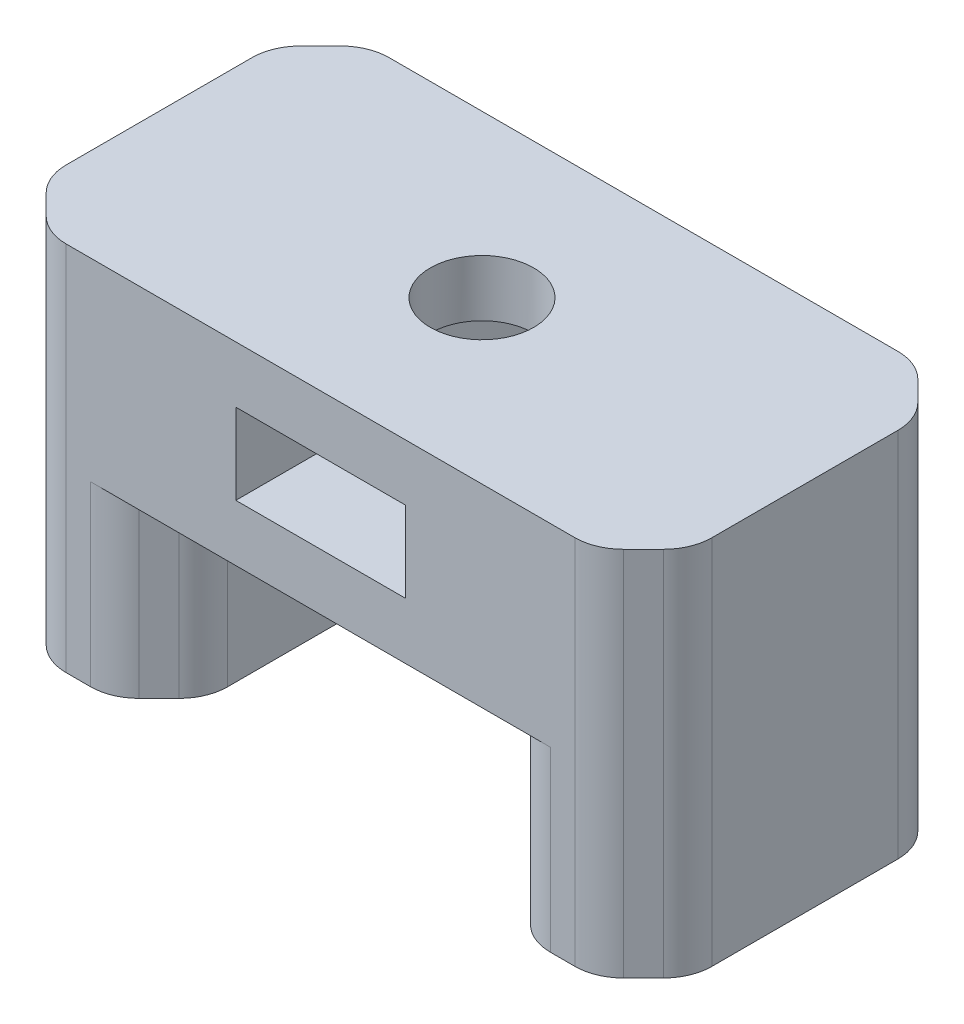
from build123d import *

# Parameters (mm, degrees)
ESQUISSE1_W             = 10
ESQUISSE1_H             = 20
BOSS_EXTRU_1_DEPTH      = 11
BOSS_EXTRU_1_2_DEPTH    = 11
ESQUISSE3_W             = 40
ESQUISSE3_H             = 20
BOSS_EXTRU_2_DEPTH      = 12
ENL_V_MAT_EXTRU_1_REACH = 34.078
ESQUISSE4_R             = 3.2
ESQUISSE1_3_R           = 2.75
ENL_V_MAT_EXTRU_3_DEPTH = 15
ESQUISSE1_4_R           = 3.5
ESQUISSE1_4_R_2         = 2.75
ENL_V_MAT_EXTRU_4_DEPTH = 1
CHANFREIN1_SIZE         = 3
CONG_1_R                = 3
ESQUISSE6_W             = 10.5
ESQUISSE6_H             = 20
ENL_V_MAT_EXTRU_5_DEPTH = 5


with BuildPart() as part:
    # Esquisse1 → Boss.-Extru.1 (new body)
    with BuildSketch(Plane(origin=(0, 0, 0), x_dir=(1, 0, 0), z_dir=(0, 1, 0))):
        with Locations((-15, 0)):
            Rectangle(ESQUISSE1_W, ESQUISSE1_H)
    extrude(amount=BOSS_EXTRU_1_DEPTH)



with BuildPart() as body_2:
    # Esquisse1 → Boss.-Extru.1 2 (new body)
    with BuildSketch(Plane(origin=(0, 0, 0), x_dir=(1, 0, 0), z_dir=(0, 1, 0))):
        with Locations((15, 0)):
            Rectangle(ESQUISSE1_W, ESQUISSE1_H)
    extrude(amount=BOSS_EXTRU_1_2_DEPTH)


with BuildPart() as part_1:
    add(part.part)

    add(body_2.part)  # Boss.-Extru.2 merges body 2
    # Esquisse3 → Boss.-Extru.2 (add)
    with BuildSketch(Plane(origin=(0, 11, 0), x_dir=(1, 0, 0), z_dir=(0, 1, 0))):
        Rectangle(ESQUISSE3_W, ESQUISSE3_H)
    extrude(amount=BOSS_EXTRU_2_DEPTH)

    # Esquisse4 → Enl_v. mat.-Extru.1 (cut, up to next)
    with BuildSketch(Plane(origin=(0, 23, 0), x_dir=(1, 0, 0), z_dir=(0, 1, 0)), mode=Mode.PRIVATE) as enl_v_mat_extru_1_sk1:
        Circle(ESQUISSE4_R)
    enl_v_mat_extru_1_tool1 = extrude(enl_v_mat_extru_1_sk1.sketch, amount=-ENL_V_MAT_EXTRU_1_REACH, mode=Mode.PRIVATE) & part_1.part
    add(enl_v_mat_extru_1_tool1.solids().sort_by_distance((0, 23, 0))[0], mode=Mode.SUBTRACT)

    # Esquisse1_3 → Enl_v. mat.-Extru.3 (cut)
    with BuildSketch(Plane(origin=(0, 0, 0), x_dir=(1, 0, 0), z_dir=(0, 1, 0))):
        with Locations((-15, 0)):
            Circle(ESQUISSE1_3_R)
        with Locations((15, 0)):
            Circle(ESQUISSE1_3_R)
    extrude(amount=ENL_V_MAT_EXTRU_3_DEPTH, mode=Mode.SUBTRACT)

    # Esquisse1_4 → Enl_v. mat.-Extru.4 (cut)
    # profile 1 of 2: a face of its own
    with BuildSketch(Plane(origin=(0, 0, 0), x_dir=(1, 0, 0), z_dir=(0, 1, 0))):
        with Locations((-15, 0)):
            Circle(ESQUISSE1_4_R)
        with Locations((-15, 0)):
            Circle(ESQUISSE1_4_R_2, mode=Mode.SUBTRACT)
    # profile 2 of 2: a face of its own
    with BuildSketch(Plane(origin=(0, 0, 0), x_dir=(1, 0, 0), z_dir=(0, 1, 0))):
        with Locations((15, 0)):
            Circle(ESQUISSE1_4_R)
        with Locations((15, 0)):
            Circle(ESQUISSE1_4_R_2, mode=Mode.SUBTRACT)
    extrude(amount=ENL_V_MAT_EXTRU_4_DEPTH, mode=Mode.SUBTRACT)

    # Chanfrein1
    chanfrein1_edges = [part_1.edges().sort_by_distance(p)[0] for p in [
        (10, 5.5, -10),
        (20, 11.5, -10),
        (10, 5.5, 10),
        (-10, 5.5, -10),
        (-10, 5.5, 10),
        (20, 11.5, 10),
        (-20, 11.5, -10),
        (-20, 11.5, 10),
    ]]
    chamfer(chanfrein1_edges, length=CHANFREIN1_SIZE)

    # Cong_1
    cong_1_edges = [part_1.edges().sort_by_distance(p)[0] for p in [
        (-10, 5.5, -7),
        (-13, 5.5, -10),
        (10, 5.5, -7),
        (13, 5.5, -10),
        (13, 5.5, 10),
        (17, 11.5, 10),
        (20, 11.5, 7),
        (20, 11.5, -7),
        (17, 11.5, -10),
        (-17, 11.5, -10),
        (-20, 11.5, -7),
        (-20, 11.5, 7),
        (-17, 11.5, 10),
        (-10, 5.5, 7),
        (-13, 5.5, 10),
        (10, 5.5, 7),
    ]]
    fillet(cong_1_edges, radius=CONG_1_R)

    # Esquisse6 → Enl_v. mat.-Extru.5 (cut)
    with BuildSketch(Plane(origin=(0, 14.5, 0), x_dir=(-1, 0, 0), z_dir=(0, -1, 0))):
        Rectangle(ESQUISSE6_W, ESQUISSE6_H)
    extrude(amount=-ENL_V_MAT_EXTRU_5_DEPTH, mode=Mode.SUBTRACT)


solid = part_1.part
